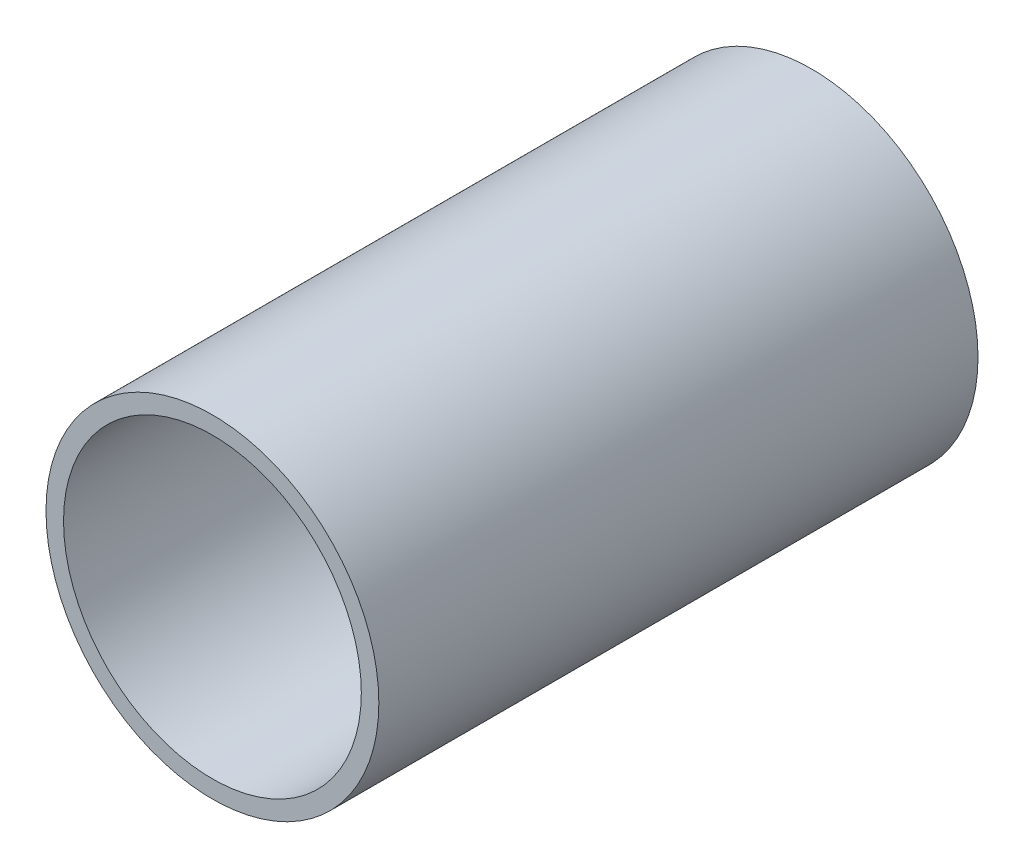
from build123d import *

# Parameters (mm, degrees)
SKETCH1_R           = 57.15
SKETCH1_R_2         = 51.1302
EXTRUDE_THIN1_DEPTH = 102.875


with BuildPart() as part:
    # Sketch1 → Extrude-Thin1 (new body, symmetric)
    with BuildSketch(Plane.XY):
        Circle(SKETCH1_R)
        Circle(SKETCH1_R_2, mode=Mode.SUBTRACT)
    extrude(amount=EXTRUDE_THIN1_DEPTH, both=True)


solid = part.part
